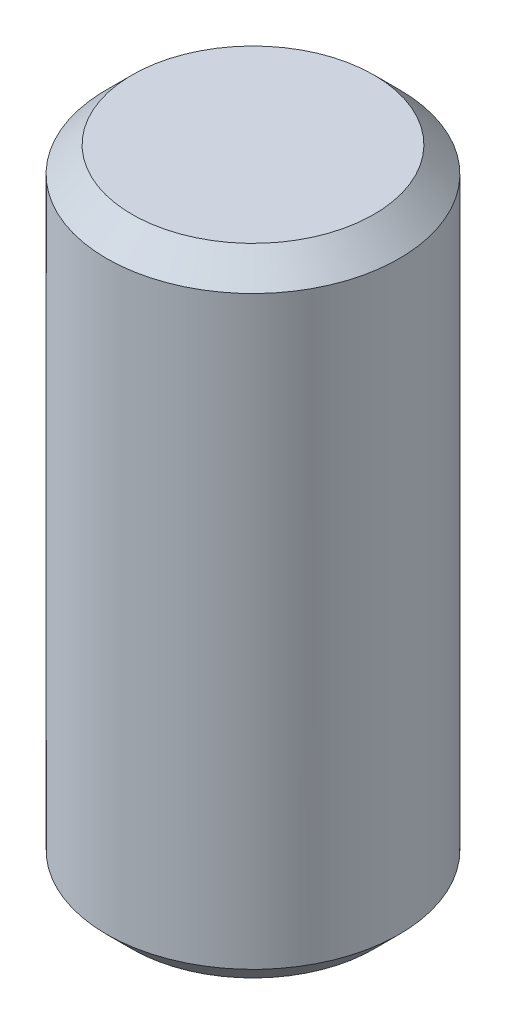
from build123d import *

# Parameters (mm, degrees)
SKETCH1_W     = 2.921
SKETCH1_H     = 12.7
CHAMFER1_SIZE = 0.508


with BuildPart() as part:
    # Sketch1 → Revolve1 (revolve)
    with BuildSketch(Plane.XY):
        with Locations((1.4605, 0)):
            Rectangle(SKETCH1_W, SKETCH1_H)
    revolve(axis=Axis((0, 6.080207887, 0), (0, -1, 0)))

    # Chamfer1
    chamfer1_edges = [part.edges().sort_by_distance(p)[0] for p in [
        (-2.921, 6.35, 0),
        (-2.921, -6.35, 0),
    ]]
    chamfer(chamfer1_edges, length=CHAMFER1_SIZE)


solid = part.part
